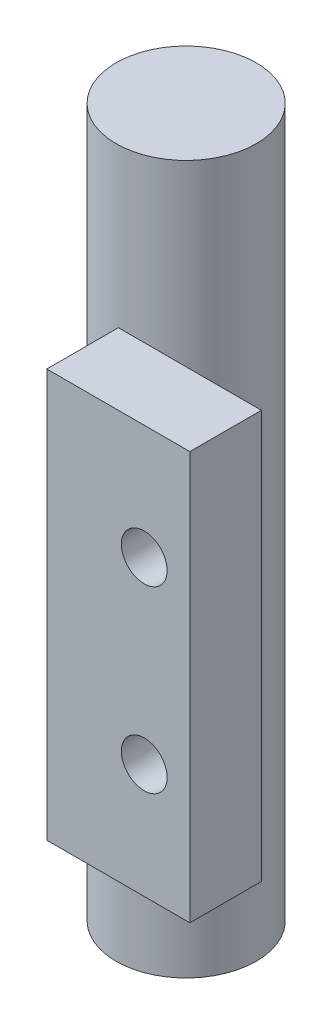
from build123d import *

# Parameters (mm, degrees)
SKETCH1_W           = 10
SKETCH1_H           = 28.53
BOSS_EXTRUDE1_DEPTH = 5
SKETCH2_R           = 1.6
CUT_EXTRUDE2_DEPTH  = 43
SKETCH10_R          = 4.9
BOSS_EXTRUDE7_DEPTH = 49.5


with BuildPart() as part:
    # Sketch1 → Boss-Extrude1 (new body)
    with BuildSketch(Plane.XY):
        with Locations((5, -15.735)):
            Rectangle(SKETCH1_W, SKETCH1_H)
    extrude(amount=BOSS_EXTRUDE1_DEPTH)

    # Sketch2 → Cut-Extrude2 (cut)
    with BuildSketch(Plane(origin=(0, 0, 0), x_dir=(-1, 0, 0), z_dir=(0, 0, -1))):
        with Locations((-6.810310374, -9.47)):
            Circle(SKETCH2_R)
        with Locations((-6.810310374, -22)):
            Circle(SKETCH2_R)
    extrude(amount=-CUT_EXTRUDE2_DEPTH, mode=Mode.SUBTRACT)


with BuildPart() as body_2:
    # Sketch10 → Boss-Extrude7 (new body)
    with BuildSketch(Plane.XZ.offset(40.965189842)):
        with Locations((-1.214108885, -5.955533219)):
            Circle(SKETCH10_R)
    extrude(amount=-BOSS_EXTRUDE7_DEPTH)


solid = Compound([part.part, body_2.part])
